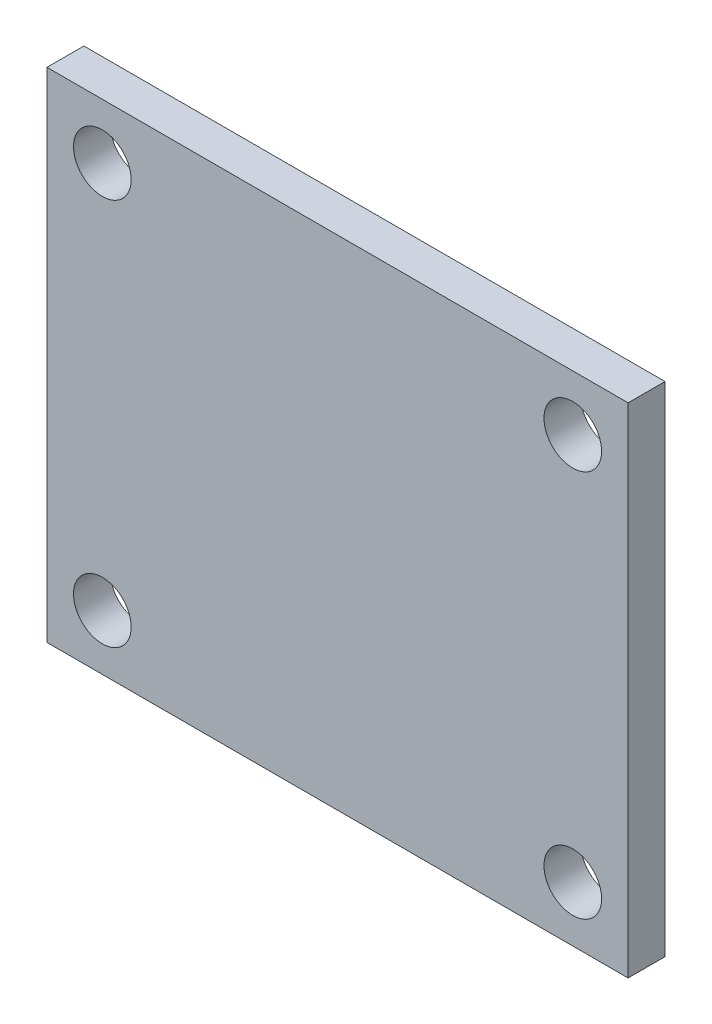
from build123d import *

# Parameters (mm, degrees)
SKETCH1_W           = 31.5
SKETCH1_H           = 27
SKETCH1_R           = 1.5625
BOSS_EXTRUDE1_DEPTH = 2
SKETCH1_3_W         = 12
SKETCH1_3_H         = 8
BOSS_EXTRUDE2_DEPTH = 1
SKETCH2_R           = 1.003384187
BOSS_EXTRUDE3_DEPTH = 0.1


with BuildPart() as part:
    # Sketch1 → Boss-Extrude1 (new body)
    with BuildSketch(Plane.XY):
        Rectangle(SKETCH1_W, SKETCH1_H)
        with Locations((-12.75, -10.5)):
            Circle(SKETCH1_R, mode=Mode.SUBTRACT)
        with Locations((12.75, -10.5)):
            Circle(SKETCH1_R, mode=Mode.SUBTRACT)
        with Locations((-12.75, 10.5)):
            Circle(SKETCH1_R, mode=Mode.SUBTRACT)
        with Locations((12.75, 10.5)):
            Circle(SKETCH1_R, mode=Mode.SUBTRACT)
    extrude(amount=BOSS_EXTRUDE1_DEPTH)

    # Sketch1_3 → Boss-Extrude2 (add)
    with BuildSketch(Plane.XY):
        Rectangle(SKETCH1_3_W, SKETCH1_3_H)
    extrude(amount=-BOSS_EXTRUDE2_DEPTH)

    # Sketch2 → Boss-Extrude3 (add)
    with BuildSketch(Plane(origin=(0, 0, -1), x_dir=(-1, 0, 0), z_dir=(0, 0, -1))):
        Circle(SKETCH2_R)
    extrude(amount=BOSS_EXTRUDE3_DEPTH)


solid = part.part
